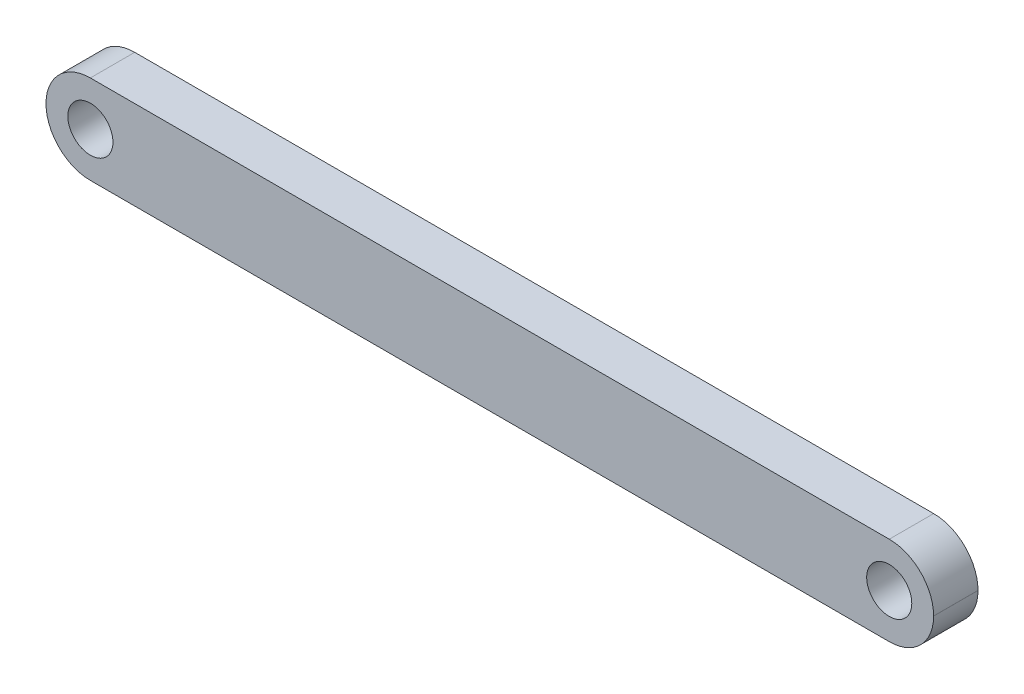
from build123d import *

# Parameters (mm, degrees)
BOSS_EXTRUDE1_DEPTH = 12.5


with BuildPart() as part:
    # Sketch1 → Boss-Extrude1 (new body)
    with BuildSketch(Plane.XY):
        with BuildLine():
            ThreePointArc((231.15, 12.5), (237.5, 18.85), (243.85, 12.5))
            Line((243.85, 12.5), (250, 12.5))
            Line((250, 12.5), (250, 12.51))
            ThreePointArc((250, 12.51), (246.341763697, 21.341763697), (237.51, 25))
            Line((237.51, 25), (12.49, 25))
            ThreePointArc((12.49, 25), (3.658236303, 21.341763697), (0, 12.51))
            Line((0, 12.51), (0, 12.5))
            Line((0, 12.5), (6.15, 12.5))
            ThreePointArc((6.15, 12.5), (12.5, 18.85), (18.85, 12.5))
            Line((18.85, 12.5), (231.15, 12.5))
        make_face()
        with BuildLine():
            Line((250, 12.5), (243.85, 12.5))
            ThreePointArc((243.85, 12.5), (237.5, 6.15), (231.15, 12.5))
            Line((231.15, 12.5), (18.85, 12.5))
            ThreePointArc((18.85, 12.5), (12.5, 6.15), (6.15, 12.5))
            Line((6.15, 12.5), (0, 12.5))
            Line((0, 12.5), (0, 12.49))
            ThreePointArc((0, 12.49), (3.658236303, 3.658236303), (12.49, 0))
            Line((12.49, 0), (237.51, 0))
            ThreePointArc((237.51, 0), (246.341763697, 3.658236303), (250, 12.49))
            Line((250, 12.49), (250, 12.5))
        make_face()
    extrude(amount=BOSS_EXTRUDE1_DEPTH)


solid = part.part
